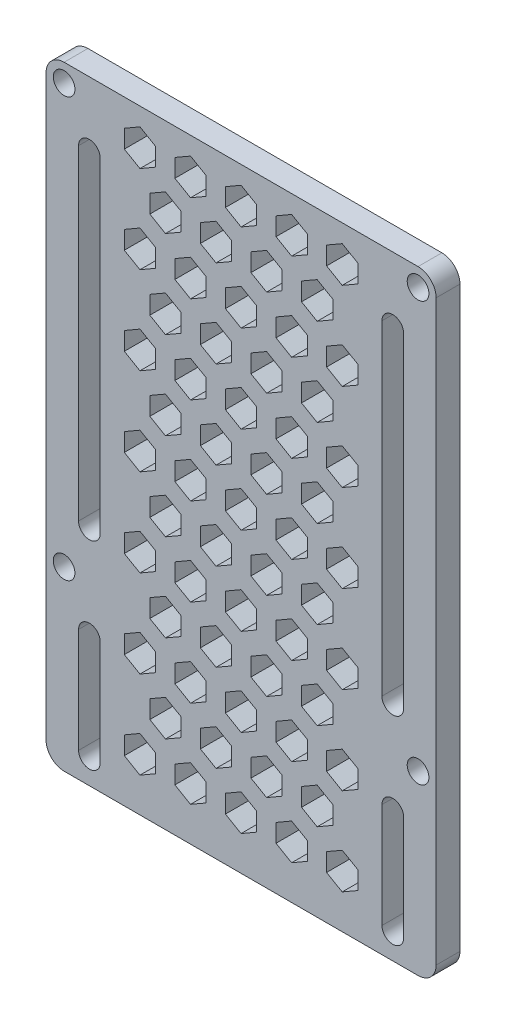
from build123d import *

# Parameters (mm, degrees)
SKETCH_1_R      = 1.5
EXTRUDE_1_DEPTH = 3.3


with BuildPart() as part:
    # 草圖1 → 填料-伸長1 (new body)
    with BuildSketch(Plane.XY):
        with BuildLine():
            Line((-19.801820626, 32.289883268), (29.198179374, 32.289883268))
            ThreePointArc((29.198179374, 32.289883268), (30.965946327, 31.557650221), (31.698179374, 29.789883268))
            Line((31.698179374, 29.789883268), (31.698179374, -28.210116732))
            Line((31.698179374, -28.210116732), (31.698179374, -50.210116732))
            ThreePointArc((31.698179374, -50.210116732), (30.965946327, -51.977883684), (29.198179374, -52.710116732))
            Line((29.198179374, -52.710116732), (-19.801820626, -52.710116732))
            ThreePointArc((-19.801820626, -52.710116732), (-21.569587579, -51.977883684), (-22.301820626, -50.210116732))
            Line((-22.301820626, -50.210116732), (-22.301820626, -28.210116732))
            Line((-22.301820626, -28.210116732), (-22.301820626, 29.789883268))
            ThreePointArc((-22.301820626, 29.789883268), (-21.569587579, 31.557650221), (-19.801820626, 32.289883268))
        make_face()
        with Locations((-19.801820626, 29.789883268)):
            Circle(SKETCH_1_R, mode=Mode.SUBTRACT)
        with Locations((29.198179374, 29.789883268)):
            Circle(SKETCH_1_R, mode=Mode.SUBTRACT)
        with Locations((29.198179374, -28.210116732)):
            Circle(SKETCH_1_R, mode=Mode.SUBTRACT)
        with Locations((-19.801820626, -28.210116732)):
            Circle(SKETCH_1_R, mode=Mode.SUBTRACT)
        with BuildLine():
            Line((-14.801820626, 23.289883268), (-14.801820626, -21.710116732))
            ThreePointArc((-14.801820626, -21.710116732), (-16.301820626, -23.210116732), (-17.801820626, -21.710116732))
            Line((-17.801820626, -21.710116732), (-17.801820626, 23.289883268))
            ThreePointArc((-17.801820626, 23.289883268), (-16.301820626, 24.789883268), (-14.801820626, 23.289883268))
        make_face(mode=Mode.SUBTRACT)
        with BuildLine():
            Line((24.198179374, 23.289883268), (24.198179374, -21.710116732))
            ThreePointArc((24.198179374, -21.710116732), (25.698179374, -23.210116732), (27.198179374, -21.710116732))
            Line((27.198179374, -21.710116732), (27.198179374, 23.289883268))
            ThreePointArc((27.198179374, 23.289883268), (25.698179374, 24.789883268), (24.198179374, 23.289883268))
        make_face(mode=Mode.SUBTRACT)
        with BuildLine():
            Line((-14.801820626, -34.710116732), (-14.801820626, -49.210116732))
            ThreePointArc((-14.801820626, -49.210116732), (-16.301820626, -50.710116732), (-17.801820626, -49.210116732))
            Line((-17.801820626, -49.210116732), (-17.801820626, -34.710116732))
            ThreePointArc((-17.801820626, -34.710116732), (-16.301820626, -33.210116732), (-14.801820626, -34.710116732))
        make_face(mode=Mode.SUBTRACT)
        with BuildLine():
            Line((24.198179374, -34.710116732), (24.198179374, -49.210116732))
            ThreePointArc((24.198179374, -49.210116732), (25.698179374, -50.710116732), (27.198179374, -49.210116732))
            Line((27.198179374, -49.210116732), (27.198179374, -34.710116732))
            ThreePointArc((27.198179374, -34.710116732), (25.698179374, -33.210116732), (24.198179374, -34.710116732))
        make_face(mode=Mode.SUBTRACT)
        Polygon((6.863242884, 28.539883268), (4.698179374, 29.789883268), (2.533115865, 28.539883268), (2.533115865, 26.039883268), (4.698179374, 24.789883268), (6.863242884, 26.039883268), align=None, mode=Mode.SUBTRACT)
        Polygon((13.863242884, 28.539883268), (11.698179374, 29.789883268), (9.533115865, 28.539883268), (9.533115865, 26.039883268), (11.698179374, 24.789883268), (13.863242884, 26.039883268), align=None, mode=Mode.SUBTRACT)
        Polygon((20.863242884, 28.539883268), (18.698179374, 29.789883268), (16.533115865, 28.539883268), (16.533115865, 26.039883268), (18.698179374, 24.789883268), (20.863242884, 26.039883268), align=None, mode=Mode.SUBTRACT)
        Polygon((-0.136757116, 28.539883268), (-2.301820626, 29.789883268), (-4.466884135, 28.539883268), (-4.466884135, 26.039883268), (-2.301820626, 24.789883268), (-0.136757116, 26.039883268), align=None, mode=Mode.SUBTRACT)
        Polygon((-7.136757116, 28.539883268), (-9.301820626, 29.789883268), (-11.466884135, 28.539883268), (-11.466884135, 26.039883268), (-9.301820626, 24.789883268), (-7.136757116, 26.039883268), align=None, mode=Mode.SUBTRACT)
        Polygon((10.394092942, 19.995370063), (10.394092942, 22.495370063), (8.229029433, 23.745370063), (6.063965923, 22.495370063), (6.063965923, 19.995370063), (8.229029433, 18.745370063), align=None, mode=Mode.SUBTRACT)
        Polygon((3.394092942, 19.995370063), (3.394092942, 22.495370063), (1.229029433, 23.745370063), (-0.936034077, 22.495370063), (-0.936034077, 19.995370063), (1.229029433, 18.745370063), align=None, mode=Mode.SUBTRACT)
        Polygon((17.394092942, 19.995370063), (17.394092942, 22.495370063), (15.229029433, 23.745370063), (13.063965923, 22.495370063), (13.063965923, 19.995370063), (15.229029433, 18.745370063), align=None, mode=Mode.SUBTRACT)
        Polygon((-3.605879199, 20.01511919), (-3.605879199, 22.51511919), (-5.770942708, 23.76511919), (-7.936006218, 22.51511919), (-7.936006218, 20.01511919), (-5.770942708, 18.76511919), align=None, mode=Mode.SUBTRACT)
        Polygon((-7.136757116, 16.415234278), (-9.301820626, 17.665234278), (-11.466884135, 16.415234278), (-11.466884135, 13.915234278), (-9.301820626, 12.665234278), (-7.136757116, 13.915234278), align=None, mode=Mode.SUBTRACT)
        Polygon((-3.605879199, 7.8904702), (-3.605879199, 10.3904702), (-5.770942708, 11.6404702), (-7.936006218, 10.3904702), (-7.936006218, 7.8904702), (-5.770942708, 6.6404702), align=None, mode=Mode.SUBTRACT)
        Polygon((-0.136757116, 16.415234278), (-2.301820626, 17.665234278), (-4.466884135, 16.415234278), (-4.466884135, 13.915234278), (-2.301820626, 12.665234278), (-0.136757116, 13.915234278), align=None, mode=Mode.SUBTRACT)
        Polygon((3.394092942, 7.870721072), (3.394092942, 10.370721072), (1.229029433, 11.620721072), (-0.936034077, 10.370721072), (-0.936034077, 7.870721072), (1.229029433, 6.620721072), align=None, mode=Mode.SUBTRACT)
        Polygon((6.863242884, 16.415234278), (4.698179374, 17.665234278), (2.533115865, 16.415234278), (2.533115865, 13.915234278), (4.698179374, 12.665234278), (6.863242884, 13.915234278), align=None, mode=Mode.SUBTRACT)
        Polygon((13.863242884, 16.415234278), (11.698179374, 17.665234278), (9.533115865, 16.415234278), (9.533115865, 13.915234278), (11.698179374, 12.665234278), (13.863242884, 13.915234278), align=None, mode=Mode.SUBTRACT)
        Polygon((20.863242884, 16.415234278), (18.698179374, 17.665234278), (16.533115865, 16.415234278), (16.533115865, 13.915234278), (18.698179374, 12.665234278), (20.863242884, 13.915234278), align=None, mode=Mode.SUBTRACT)
        Polygon((17.394092942, 7.870721072), (17.394092942, 10.370721072), (15.229029433, 11.620721072), (13.063965923, 10.370721072), (13.063965923, 7.870721072), (15.229029433, 6.620721072), align=None, mode=Mode.SUBTRACT)
        Polygon((10.394092942, 7.870721072), (10.394092942, 10.370721072), (8.229029433, 11.620721072), (6.063965923, 10.370721072), (6.063965923, 7.870721072), (8.229029433, 6.620721072), align=None, mode=Mode.SUBTRACT)
        Polygon((-3.605879199, -4.2295298), (-3.605879199, -1.7295298), (-5.770942708, -0.4795298), (-7.936006218, -1.7295298), (-7.936006218, -4.2295298), (-5.770942708, -5.4795298), align=None, mode=Mode.SUBTRACT)
        Polygon((-7.136757116, 4.295234278), (-9.301820626, 5.545234278), (-11.466884135, 4.295234278), (-11.466884135, 1.795234278), (-9.301820626, 0.545234278), (-7.136757116, 1.795234278), align=None, mode=Mode.SUBTRACT)
        Polygon((-0.136757116, 4.295234278), (-2.301820626, 5.545234278), (-4.466884135, 4.295234278), (-4.466884135, 1.795234278), (-2.301820626, 0.545234278), (-0.136757116, 1.795234278), align=None, mode=Mode.SUBTRACT)
        Polygon((3.394092942, -4.249278928), (3.394092942, -1.749278928), (1.229029433, -0.499278928), (-0.936034077, -1.749278928), (-0.936034077, -4.249278928), (1.229029433, -5.499278928), align=None, mode=Mode.SUBTRACT)
        Polygon((10.394092942, -4.249278928), (10.394092942, -1.749278928), (8.229029433, -0.499278928), (6.063965923, -1.749278928), (6.063965923, -4.249278928), (8.229029433, -5.499278928), align=None, mode=Mode.SUBTRACT)
        Polygon((6.863242884, 4.295234278), (4.698179374, 5.545234278), (2.533115865, 4.295234278), (2.533115865, 1.795234278), (4.698179374, 0.545234278), (6.863242884, 1.795234278), align=None, mode=Mode.SUBTRACT)
        Polygon((13.863242884, 4.295234278), (11.698179374, 5.545234278), (9.533115865, 4.295234278), (9.533115865, 1.795234278), (11.698179374, 0.545234278), (13.863242884, 1.795234278), align=None, mode=Mode.SUBTRACT)
        Polygon((20.863242884, 4.295234278), (18.698179374, 5.545234278), (16.533115865, 4.295234278), (16.533115865, 1.795234278), (18.698179374, 0.545234278), (20.863242884, 1.795234278), align=None, mode=Mode.SUBTRACT)
        Polygon((17.394092942, -4.249278928), (17.394092942, -1.749278928), (15.229029433, -0.499278928), (13.063965923, -1.749278928), (13.063965923, -4.249278928), (15.229029433, -5.499278928), align=None, mode=Mode.SUBTRACT)
        Polygon((-3.605879199, -16.3495298), (-3.605879199, -13.8495298), (-5.770942708, -12.5995298), (-7.936006218, -13.8495298), (-7.936006218, -16.3495298), (-5.770942708, -17.5995298), align=None, mode=Mode.SUBTRACT)
        Polygon((-7.136757116, -7.824765722), (-9.301820626, -6.574765722), (-11.466884135, -7.824765722), (-11.466884135, -10.324765722), (-9.301820626, -11.574765722), (-7.136757116, -10.324765722), align=None, mode=Mode.SUBTRACT)
        Polygon((-0.136757116, -7.824765722), (-2.301820626, -6.574765722), (-4.466884135, -7.824765722), (-4.466884135, -10.324765722), (-2.301820626, -11.574765722), (-0.136757116, -10.324765722), align=None, mode=Mode.SUBTRACT)
        Polygon((3.394092942, -16.369278928), (3.394092942, -13.869278928), (1.229029433, -12.619278928), (-0.936034077, -13.869278928), (-0.936034077, -16.369278928), (1.229029433, -17.619278928), align=None, mode=Mode.SUBTRACT)
        Polygon((10.394092942, -16.369278928), (10.394092942, -13.869278928), (8.229029433, -12.619278928), (6.063965923, -13.869278928), (6.063965923, -16.369278928), (8.229029433, -17.619278928), align=None, mode=Mode.SUBTRACT)
        Polygon((6.863242884, -7.824765722), (4.698179374, -6.574765722), (2.533115865, -7.824765722), (2.533115865, -10.324765722), (4.698179374, -11.574765722), (6.863242884, -10.324765722), align=None, mode=Mode.SUBTRACT)
        Polygon((13.863242884, -7.824765722), (11.698179374, -6.574765722), (9.533115865, -7.824765722), (9.533115865, -10.324765722), (11.698179374, -11.574765722), (13.863242884, -10.324765722), align=None, mode=Mode.SUBTRACT)
        Polygon((20.863242884, -7.824765722), (18.698179374, -6.574765722), (16.533115865, -7.824765722), (16.533115865, -10.324765722), (18.698179374, -11.574765722), (20.863242884, -10.324765722), align=None, mode=Mode.SUBTRACT)
        Polygon((17.394092942, -16.369278928), (17.394092942, -13.869278928), (15.229029433, -12.619278928), (13.063965923, -13.869278928), (13.063965923, -16.369278928), (15.229029433, -17.619278928), align=None, mode=Mode.SUBTRACT)
        Polygon((-3.605879199, -28.4695298), (-3.605879199, -25.9695298), (-5.770942708, -24.7195298), (-7.936006218, -25.9695298), (-7.936006218, -28.4695298), (-5.770942708, -29.7195298), align=None, mode=Mode.SUBTRACT)
        Polygon((-7.136757116, -19.944765722), (-9.301820626, -18.694765722), (-11.466884135, -19.944765722), (-11.466884135, -22.444765722), (-9.301820626, -23.694765722), (-7.136757116, -22.444765722), align=None, mode=Mode.SUBTRACT)
        Polygon((-0.136757116, -19.944765722), (-2.301820626, -18.694765722), (-4.466884135, -19.944765722), (-4.466884135, -22.444765722), (-2.301820626, -23.694765722), (-0.136757116, -22.444765722), align=None, mode=Mode.SUBTRACT)
        Polygon((3.394092942, -28.489278928), (3.394092942, -25.989278928), (1.229029433, -24.739278928), (-0.936034077, -25.989278928), (-0.936034077, -28.489278928), (1.229029433, -29.739278928), align=None, mode=Mode.SUBTRACT)
        Polygon((10.394092942, -28.489278928), (10.394092942, -25.989278928), (8.229029433, -24.739278928), (6.063965923, -25.989278928), (6.063965923, -28.489278928), (8.229029433, -29.739278928), align=None, mode=Mode.SUBTRACT)
        Polygon((6.863242884, -19.944765722), (4.698179374, -18.694765722), (2.533115865, -19.944765722), (2.533115865, -22.444765722), (4.698179374, -23.694765722), (6.863242884, -22.444765722), align=None, mode=Mode.SUBTRACT)
        Polygon((13.863242884, -19.944765722), (11.698179374, -18.694765722), (9.533115865, -19.944765722), (9.533115865, -22.444765722), (11.698179374, -23.694765722), (13.863242884, -22.444765722), align=None, mode=Mode.SUBTRACT)
        Polygon((20.863242884, -19.944765722), (18.698179374, -18.694765722), (16.533115865, -19.944765722), (16.533115865, -22.444765722), (18.698179374, -23.694765722), (20.863242884, -22.444765722), align=None, mode=Mode.SUBTRACT)
        Polygon((17.394092942, -28.489278928), (17.394092942, -25.989278928), (15.229029433, -24.739278928), (13.063965923, -25.989278928), (13.063965923, -28.489278928), (15.229029433, -29.739278928), align=None, mode=Mode.SUBTRACT)
        Polygon((-3.605879199, -40.5895298), (-3.605879199, -38.0895298), (-5.770942708, -36.8395298), (-7.936006218, -38.0895298), (-7.936006218, -40.5895298), (-5.770942708, -41.8395298), align=None, mode=Mode.SUBTRACT)
        Polygon((-7.136757116, -32.064765722), (-9.301820626, -30.814765722), (-11.466884135, -32.064765722), (-11.466884135, -34.564765722), (-9.301820626, -35.814765722), (-7.136757116, -34.564765722), align=None, mode=Mode.SUBTRACT)
        Polygon((-0.136757116, -32.064765722), (-2.301820626, -30.814765722), (-4.466884135, -32.064765722), (-4.466884135, -34.564765722), (-2.301820626, -35.814765722), (-0.136757116, -34.564765722), align=None, mode=Mode.SUBTRACT)
        Polygon((3.394092942, -40.609278928), (3.394092942, -38.109278928), (1.229029433, -36.859278928), (-0.936034077, -38.109278928), (-0.936034077, -40.609278928), (1.229029433, -41.859278928), align=None, mode=Mode.SUBTRACT)
        Polygon((10.394092942, -40.609278928), (10.394092942, -38.109278928), (8.229029433, -36.859278928), (6.063965923, -38.109278928), (6.063965923, -40.609278928), (8.229029433, -41.859278928), align=None, mode=Mode.SUBTRACT)
        Polygon((6.863242884, -32.064765722), (4.698179374, -30.814765722), (2.533115865, -32.064765722), (2.533115865, -34.564765722), (4.698179374, -35.814765722), (6.863242884, -34.564765722), align=None, mode=Mode.SUBTRACT)
        Polygon((13.863242884, -32.064765722), (11.698179374, -30.814765722), (9.533115865, -32.064765722), (9.533115865, -34.564765722), (11.698179374, -35.814765722), (13.863242884, -34.564765722), align=None, mode=Mode.SUBTRACT)
        Polygon((20.863242884, -32.064765722), (18.698179374, -30.814765722), (16.533115865, -32.064765722), (16.533115865, -34.564765722), (18.698179374, -35.814765722), (20.863242884, -34.564765722), align=None, mode=Mode.SUBTRACT)
        Polygon((17.394092942, -40.609278928), (17.394092942, -38.109278928), (15.229029433, -36.859278928), (13.063965923, -38.109278928), (13.063965923, -40.609278928), (15.229029433, -41.859278928), align=None, mode=Mode.SUBTRACT)
        Polygon((-7.136757116, -44.184761157), (-9.301820626, -42.934761157), (-11.466884135, -44.184761157), (-11.466884135, -46.684761157), (-9.301820626, -47.934761157), (-7.136757116, -46.684761157), align=None, mode=Mode.SUBTRACT)
        Polygon((-0.136757116, -44.184761157), (-2.301820626, -42.934761157), (-4.466884135, -44.184761157), (-4.466884135, -46.684761157), (-2.301820626, -47.934761157), (-0.136757116, -46.684761157), align=None, mode=Mode.SUBTRACT)
        Polygon((6.863242884, -44.184761157), (4.698179374, -42.934761157), (2.533115865, -44.184761157), (2.533115865, -46.684761157), (4.698179374, -47.934761157), (6.863242884, -46.684761157), align=None, mode=Mode.SUBTRACT)
        Polygon((13.863242884, -44.184761157), (11.698179374, -42.934761157), (9.533115865, -44.184761157), (9.533115865, -46.684761157), (11.698179374, -47.934761157), (13.863242884, -46.684761157), align=None, mode=Mode.SUBTRACT)
        Polygon((20.863242884, -44.184761157), (18.698179374, -42.934761157), (16.533115865, -44.184761157), (16.533115865, -46.684761157), (18.698179374, -47.934761157), (20.863242884, -46.684761157), align=None, mode=Mode.SUBTRACT)
    extrude(amount=EXTRUDE_1_DEPTH)


solid = part.part
